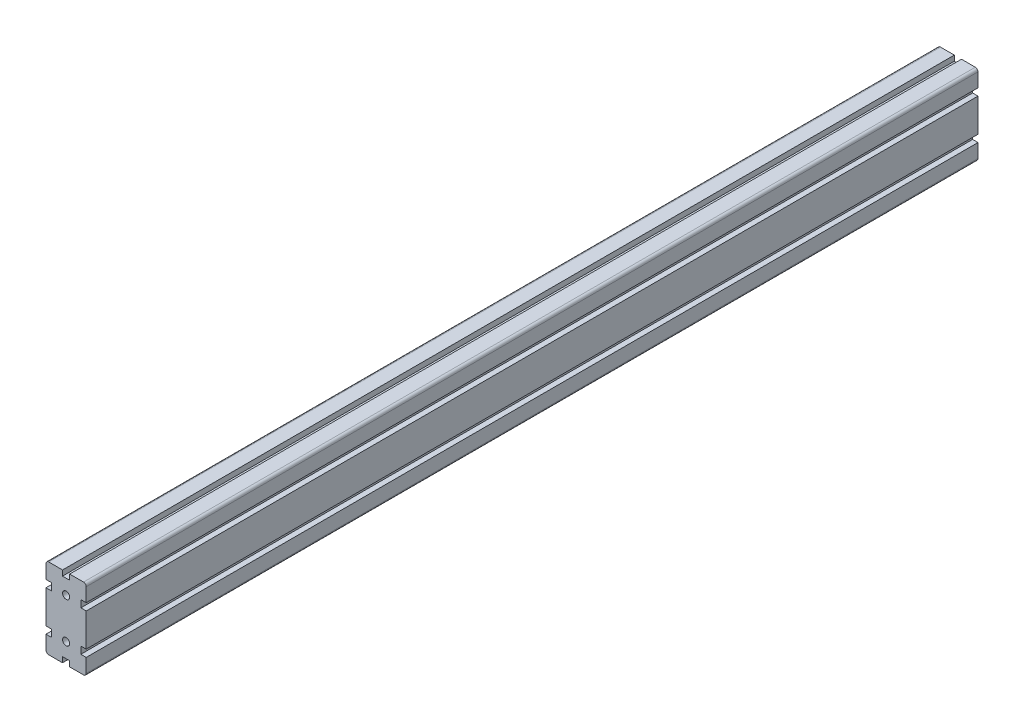
from build123d import *

# Parameters (mm, degrees)
ESQUISSE1_R        = 4
BOSS_EXTRU_1_DEPTH = 998


with BuildPart() as part:
    # Esquisse1 → Boss.-Extru.1 (new body)
    with BuildSketch(Plane(origin=(0, 0, -1000), x_dir=(-1, 0, 0), z_dir=(0, 0, -1))):
        with BuildLine():
            Line((42.288948628, 57.315448094), (48.288948628, 57.315448094))
            Line((48.288948628, 57.315448094), (48.288948628, 72.815448094))
            ThreePointArc((48.288948628, 72.815448094), (47.410268972, 74.936768437), (45.288948628, 75.815448094))
            Line((45.288948628, 75.815448094), (29.788948628, 75.815448094))
            Line((29.788948628, 75.815448094), (29.788948628, 69.815448094))
            Line((29.788948628, 69.815448094), (21.788948628, 69.815448094))
            Line((21.788948628, 69.815448094), (21.788948628, 75.815448094))
            Line((21.788948628, 75.815448094), (6.288948628, 75.815448094))
            ThreePointArc((6.288948628, 75.815448094), (4.167628284, 74.936768437), (3.288948628, 72.815448094))
            Line((3.288948628, 72.815448094), (3.288948628, 57.315448094))
            Line((3.288948628, 57.315448094), (9.288948628, 57.315448094))
            Line((9.288948628, 57.315448094), (9.288948628, 49.315448094))
            Line((9.288948628, 49.315448094), (3.288948628, 49.315448094))
            Line((3.288948628, 49.315448094), (3.288948628, 12.315448094))
            Line((3.288948628, 12.315448094), (9.288948628, 12.315448094))
            Line((9.288948628, 12.315448094), (9.288948628, 4.315448094))
            Line((9.288948628, 4.315448094), (3.288948628, 4.315448094))
            Line((3.288948628, 4.315448094), (3.288948628, -11.184551906))
            ThreePointArc((3.288948628, -11.184551906), (4.167628284, -13.30587225), (6.288948628, -14.184551906))
            Line((6.288948628, -14.184551906), (21.788948628, -14.184551906))
            Line((21.788948628, -14.184551906), (21.788948628, -8.184551906))
            Line((21.788948628, -8.184551906), (29.788948628, -8.184551906))
            Line((29.788948628, -8.184551906), (29.788948628, -14.184551906))
            Line((29.788948628, -14.184551906), (45.288948628, -14.184551906))
            ThreePointArc((45.288948628, -14.184551906), (47.410268972, -13.30587225), (48.288948628, -11.184551906))
            Line((48.288948628, -11.184551906), (48.288948628, 4.315448094))
            Line((48.288948628, 4.315448094), (42.288948628, 4.315448094))
            Line((42.288948628, 4.315448094), (42.288948628, 12.315448094))
            Line((42.288948628, 12.315448094), (48.288948628, 12.315448094))
            Line((48.288948628, 12.315448094), (48.288948628, 49.315448094))
            Line((48.288948628, 49.315448094), (42.288948628, 49.315448094))
            Line((42.288948628, 49.315448094), (42.288948628, 57.315448094))
        make_face()
        with Locations((25.788948628, 53.315448094)):
            Circle(ESQUISSE1_R, mode=Mode.SUBTRACT)
        with Locations((25.788948628, 8.315448094)):
            Circle(ESQUISSE1_R, mode=Mode.SUBTRACT)
    extrude(amount=-BOSS_EXTRU_1_DEPTH)


solid = part.part
